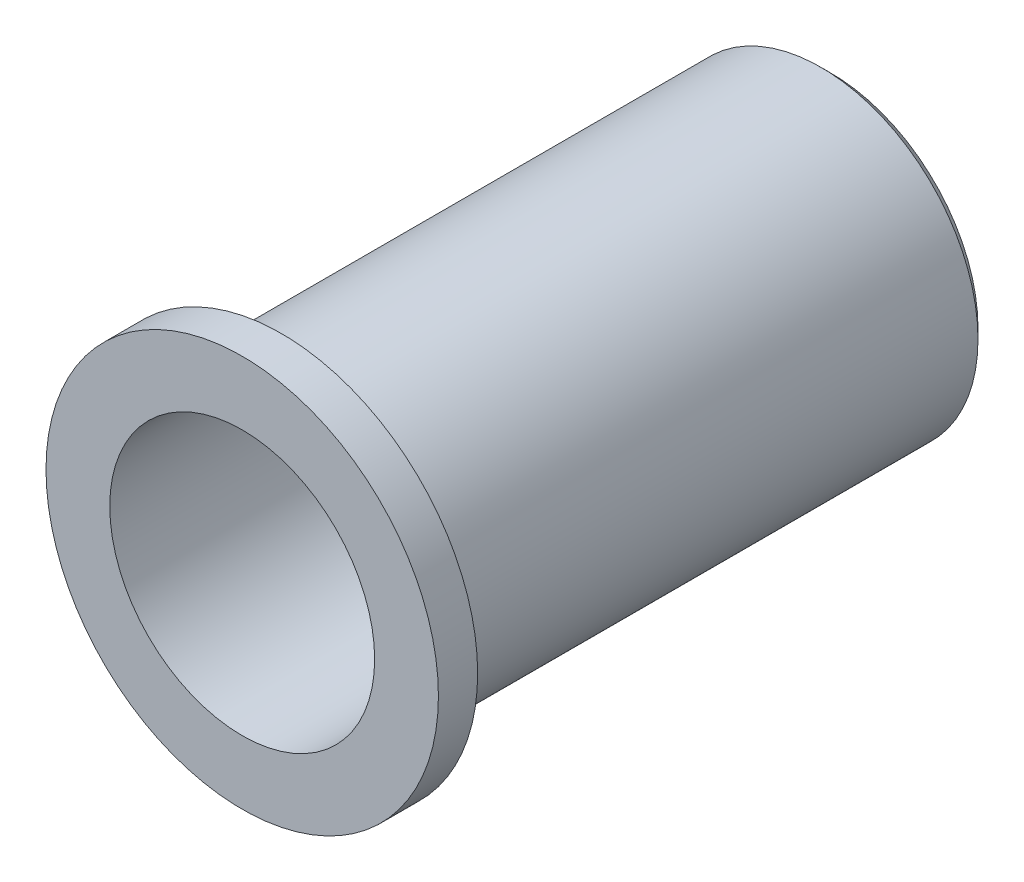
from build123d import *

# Parameters (mm, degrees)
SKETCH_1_R          = 4
EXTRUDE_1_DEPTH     = 12
SKETCH_2_R          = 2.7
CUT_EXTRUDE_1_DEPTH = 4.2
SKETCH_3_OUTSIDE_W  = 13.298
SKETCH_3_OUTSIDE_H  = 13.298
SKETCH_3_OUTSIDE_R  = 3.2
CUT_EXTRUDE_2_DEPTH = 11.2
SKETCH_4_R          = 1.6
CUT_EXTRUDE_3_DEPTH = 11.2
CHAMFER_1_SIZE      = 0.2


with BuildPart() as part:
    # Эскиз1 → Бобышка-Вытянуть1 (new body)
    with BuildSketch(Plane.XY):
        Circle(SKETCH_1_R)
    extrude(amount=EXTRUDE_1_DEPTH)

    # Эскиз2 → Вырез-Вытянуть1 (cut)
    with BuildSketch(Plane.XY.offset(12)):
        Circle(SKETCH_2_R)
    extrude(amount=-CUT_EXTRUDE_1_DEPTH, mode=Mode.SUBTRACT)

    # Эскиз3 outside → Вырез-Вытянуть2 (cut)
    with BuildSketch(Plane(origin=(0, 0, 0), x_dir=(-1, 0, 0), z_dir=(0, 0, -1))):
        Rectangle(SKETCH_3_OUTSIDE_W, SKETCH_3_OUTSIDE_H)
        Circle(SKETCH_3_OUTSIDE_R, mode=Mode.SUBTRACT)
    extrude(amount=-CUT_EXTRUDE_2_DEPTH, mode=Mode.SUBTRACT)

    # Эскиз4 → Вырез-Вытянуть3 (cut)
    with BuildSketch(Plane(origin=(0, 0, 0), x_dir=(-1, 0, 0), z_dir=(0, 0, -1))):
        Circle(SKETCH_4_R)
    extrude(amount=-CUT_EXTRUDE_3_DEPTH, mode=Mode.SUBTRACT)

    # Фаска1
    chamfer_1_edges = [part.edges().sort_by_distance(p)[0] for p in [
        (3.2, 0, 0),
    ]]
    chamfer(chamfer_1_edges, length=CHAMFER_1_SIZE)


solid = part.part
